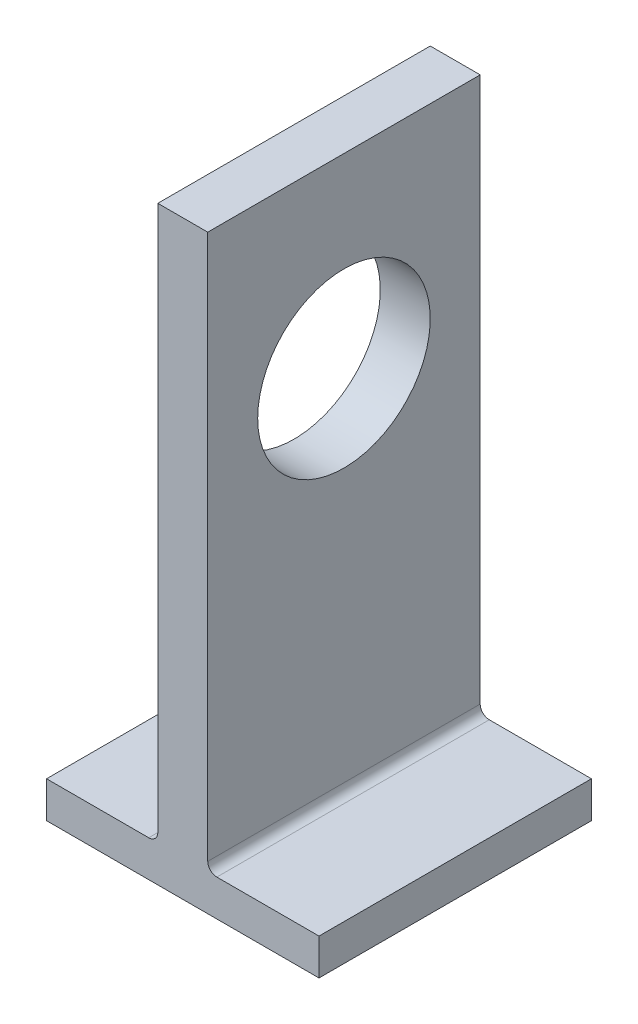
from build123d import *

# Parameters (mm, degrees)
BOSS_EXTRUDE1_DEPTH = 30
SKETCH2_R           = 9.5
CUT_EXTRUDE1_DEPTH  = 70


with BuildPart() as part:
    # Sketch1 → Boss-Extrude1 (new body)
    with BuildSketch(Plane.XY):
        with BuildLine():
            Line((3.75, 0), (15, 0))
            Line((15, 0), (15, -4))
            Line((15, -4), (-15, -4))
            Line((-15, -4), (-15, 0))
            Line((-15, 0), (-3.75, 0))
            ThreePointArc((-3.75, 0), (-3.042893219, 0.292893219), (-2.75, 1))
            Line((-2.75, 1), (-2.75, 61))
            Line((-2.75, 61), (2.75, 61))
            Line((2.75, 61), (2.75, 1))
            ThreePointArc((2.75, 1), (3.042893219, 0.292893219), (3.75, 0))
        make_face()
    extrude(amount=BOSS_EXTRUDE1_DEPTH)

    # Sketch2 → Cut-Extrude1 (cut)
    with BuildSketch(Plane.ZY.offset(2.75)):
        with Locations((15, 40.5)):
            Circle(SKETCH2_R)
    extrude(amount=-CUT_EXTRUDE1_DEPTH, mode=Mode.SUBTRACT)


solid = part.part
